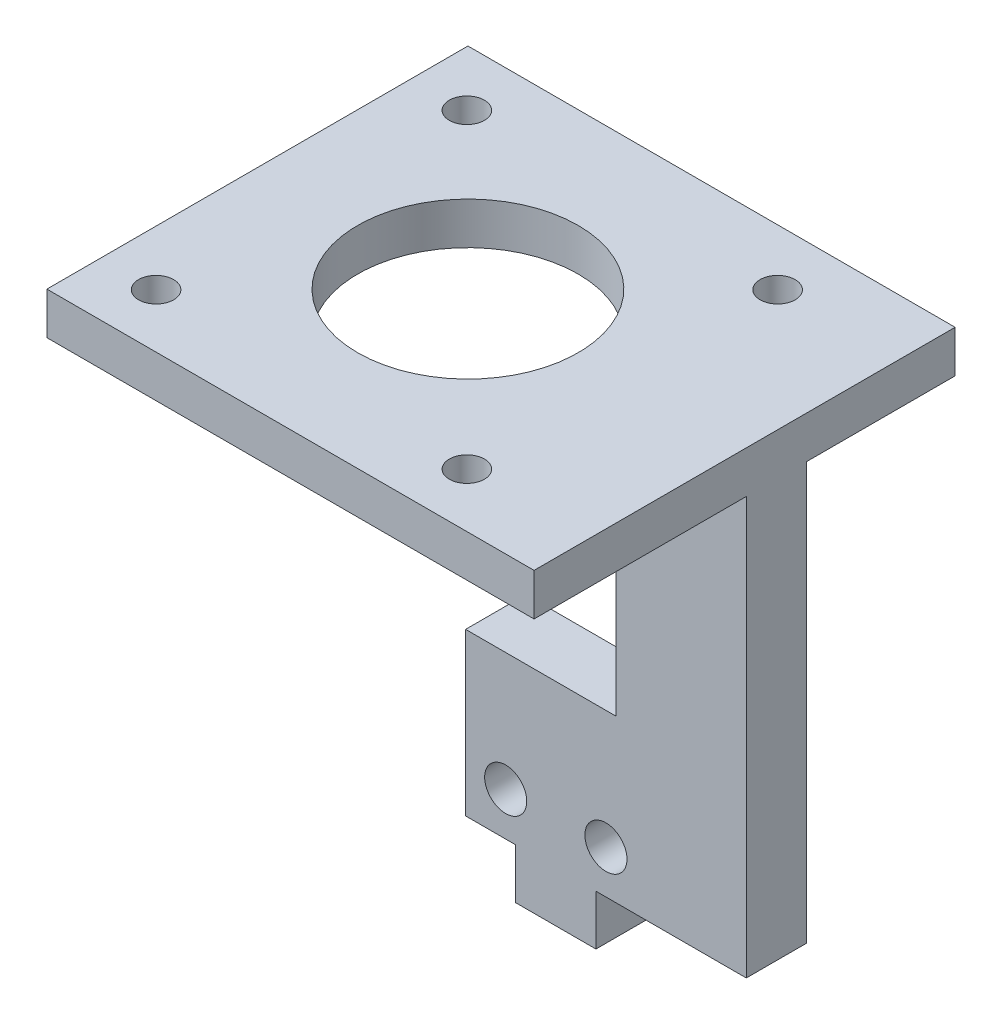
from build123d import *

# Parameters (mm, degrees)
SKETCH_1_W          = 18
SKETCH_1_H          = 50
EXTRUDE_1_DEPTH     = 6
SKETCH_3_R          = 2.1
CUT_EXTRUDE_2_DEPTH = 6
SKETCH_4_W          = 8
SKETCH_4_H          = 10
EXTRUDE_2_DEPTH     = 5
SKETCH_5_W          = 6
SKETCH_5_H          = 50
EXTRUDE_3_DEPTH     = 10
SKETCH_6_W          = 15
SKETCH_6_H          = 33.880633875
CUT_EXTRUDE_3_DEPTH = 10
SKETCH_7_W          = 18.194641251
SKETCH_7_H          = 8.438338953
CUT_EXTRUDE_4_DEPTH = 4.2
SKETCH_8_W          = 58.547266504
SKETCH_8_H          = 42
EXTRUDE_4_DEPTH     = 4.2
SKETCH_9_W          = 49.225807408
SKETCH_9_H          = 6.051517764
CUT_EXTRUDE_5_DEPTH = 9.95
SKETCH_15_R         = 1.75
CUT_EXTRUDE_6_DEPTH = 9.95
SKETCH_16_R         = 11
CUT_EXTRUDE_7_DEPTH = 10


with BuildPart() as part:
    # 草图1 → 凸台-拉伸1 (new body)
    with BuildSketch(Plane.XY):
        with Locations((9, 25)):
            Rectangle(SKETCH_1_W, SKETCH_1_H)
    extrude(amount=EXTRUDE_1_DEPTH)

    # 草图3 → 切除-拉伸2 (cut)
    with BuildSketch(Plane.XY.offset(6)):
        with Locations((4, 4.30447472)):
            Circle(SKETCH_3_R)
        with Locations((14, 4.30447472)):
            Circle(SKETCH_3_R)
    extrude(amount=-CUT_EXTRUDE_2_DEPTH, mode=Mode.SUBTRACT)

    # 草图4 → 凸台-拉伸2 (add)
    with BuildSketch(Plane.XZ):
        with Locations((9, 1)):
            Rectangle(SKETCH_4_W, SKETCH_4_H)
    extrude(amount=EXTRUDE_2_DEPTH)

    # 草图5 → 凸台-拉伸3 (add)
    with BuildSketch(Plane(origin=(18, 0, 0), x_dir=(0, 0, -1), z_dir=(1, 0, 0))):
        with Locations((-3, 25)):
            Rectangle(SKETCH_5_W, SKETCH_5_H)
    extrude(amount=EXTRUDE_3_DEPTH)

    # 草图6 → 切除-拉伸3 (cut)
    with BuildSketch(Plane.XY.offset(6)):
        with Locations((7.5, 33.059683062)):
            Rectangle(SKETCH_6_W, SKETCH_6_H)
    extrude(amount=-CUT_EXTRUDE_3_DEPTH, mode=Mode.SUBTRACT)

    # 草图7 → 切除-拉伸4 (cut)
    with BuildSketch(Plane(origin=(0, 50, 0), x_dir=(1, 0, 0), z_dir=(0, 1, 0))):
        with Locations((18.902679374, -1.780830523)):
            Rectangle(SKETCH_7_W, SKETCH_7_H)
    extrude(amount=-CUT_EXTRUDE_4_DEPTH, mode=Mode.SUBTRACT)

    # 草图8 → 凸台-拉伸4 (add)
    with BuildSketch(Plane(origin=(0, 45.8, 0), x_dir=(1, 0, 0), z_dir=(0, 1, 0))):
        with Locations((-1.273633252, -6.17)):
            Rectangle(SKETCH_8_W, SKETCH_8_H)
    extrude(amount=-EXTRUDE_4_DEPTH)

    # 草图9 → 切除-拉伸5 (cut)
    with BuildSketch(Plane.ZY.offset(30.547266504)):
        with Locations((2.557096296, 42.774241118)):
            Rectangle(SKETCH_9_W, SKETCH_9_H)
    extrude(amount=-CUT_EXTRUDE_5_DEPTH, mode=Mode.SUBTRACT)

    # 草图15 → 切除-拉伸6 (cut)
    with BuildSketch(Plane.XZ.offset(-41.6)):
        with Locations((15.90237217, -9.22379542)):
            Circle(SKETCH_15_R)
        with Locations((-15.09762783, -9.22379542)):
            Circle(SKETCH_15_R)
        with Locations((15.90237217, 21.77620458)):
            Circle(SKETCH_15_R)
        with Locations((-15.09762783, 21.77620458)):
            Circle(SKETCH_15_R)
    extrude(amount=-CUT_EXTRUDE_6_DEPTH, mode=Mode.SUBTRACT)

    # 草图16 → 切除-拉伸7 (cut)
    with BuildSketch(Plane.XZ.offset(-41.6)):
        with Locations((0.4, 6.17)):
            Circle(SKETCH_16_R)
    extrude(amount=-CUT_EXTRUDE_7_DEPTH, mode=Mode.SUBTRACT)


solid = part.part
